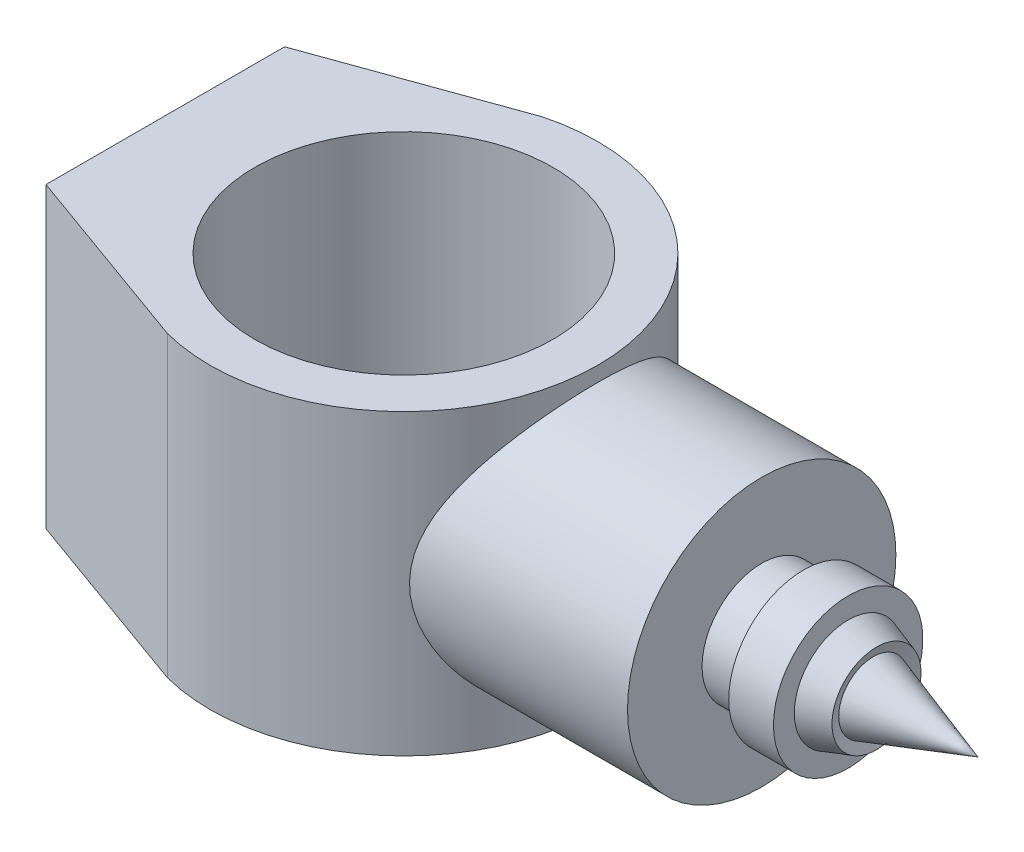
from build123d import *

# Parameters (mm, degrees)
SKETCH1_R           = 50
BOSS_EXTRUDE1_DEPTH = 50
BOSS_EXTRUDE2_REACH = 202
SKETCH2_R           = 45


with BuildPart() as part:
    # Sketch1 → Boss-Extrude1 (new body, symmetric)
    with BuildSketch(Plane(origin=(0, 0, 0), x_dir=(1, 0, 0), z_dir=(0, 1, 0))):
        with BuildLine():
            Line((-80, -40), (-80, 40))
            Line((-80, 40), (-16.407423315, 62.895122706))
            ThreePointArc((-16.407423315, 62.895122706), (65, 0), (-16.407423315, -62.895122706))
            Line((-16.407423315, -62.895122706), (-80, -40))
        make_face()
        Circle(SKETCH1_R, mode=Mode.SUBTRACT)
    extrude(amount=BOSS_EXTRUDE1_DEPTH, both=True)

    # Sketch2 → Boss-Extrude2 (add, up to next)
    with BuildSketch(Plane(origin=(120, 0, 0), x_dir=(0, 0, -1), z_dir=(1, 0, 0)), mode=Mode.PRIVATE) as boss_extrude2_sk1:
        Circle(SKETCH2_R)
    boss_extrude2_tool1 = extrude(boss_extrude2_sk1.sketch, amount=-BOSS_EXTRUDE2_REACH, mode=Mode.PRIVATE) - part.part
    add(boss_extrude2_tool1.solids().sort_by_distance((120, 0, 0))[0])

    # Sketch3 → Revolve1 (revolve)
    with BuildSketch(Plane(origin=(0, 0, 0), x_dir=(1, 0, 0), z_dir=(0, 1, 0))):
        Polygon((120, 0), (120, -20), (134, -20), (134, -25.051306185), (149, -25.051306185), (149, -18.051306185), (158.499342873, -14.926808627), (157.392152325, -11.560640965), (192.539720953, 0), align=None)
    revolve(axis=Axis((0, 0, 0), (1, 0, 0)))


solid = part.part
